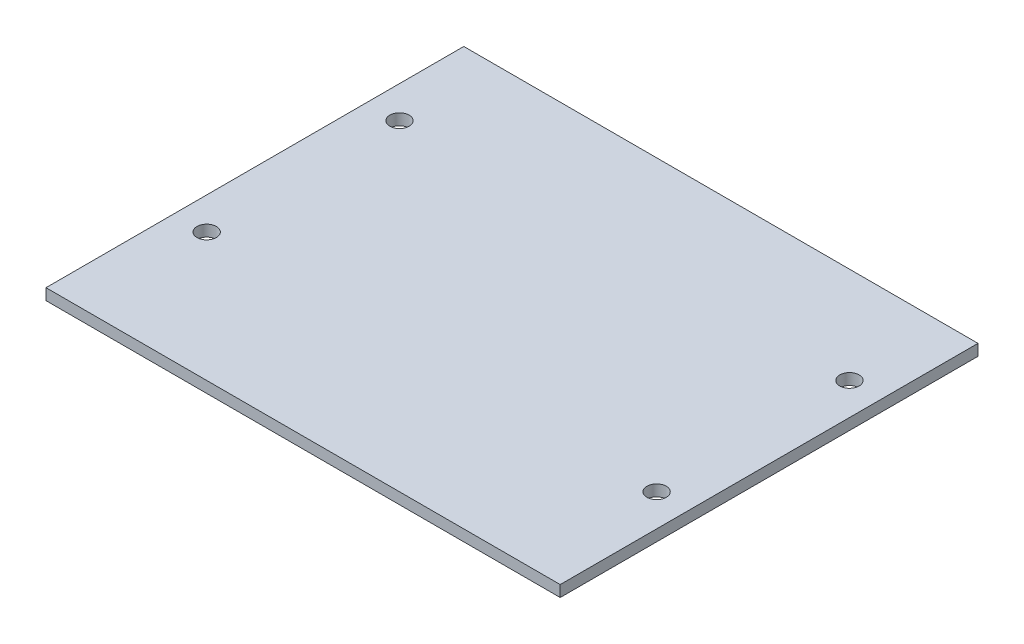
from build123d import *

# Parameters (mm, degrees)
SKETCH1_W           = 80
SKETCH1_H           = 65
SKETCH1_R           = 1.5025
BOSS_EXTRUDE1_DEPTH = 1.75


with BuildPart() as part:
    # Sketch1 → Boss-Extrude1 (new body)
    with BuildSketch(Plane(origin=(0, 0, 0), x_dir=(1, 0, 0), z_dir=(0, 1, 0))):
        Rectangle(SKETCH1_W, SKETCH1_H)
        with Locations((-35, -12.5)):
            Circle(SKETCH1_R, mode=Mode.SUBTRACT)
        with Locations((35, -12.5)):
            Circle(SKETCH1_R, mode=Mode.SUBTRACT)
        with Locations((35, 17.5)):
            Circle(SKETCH1_R, mode=Mode.SUBTRACT)
        with Locations((-35, 17.5)):
            Circle(SKETCH1_R, mode=Mode.SUBTRACT)
    extrude(amount=BOSS_EXTRUDE1_DEPTH)


solid = part.part
